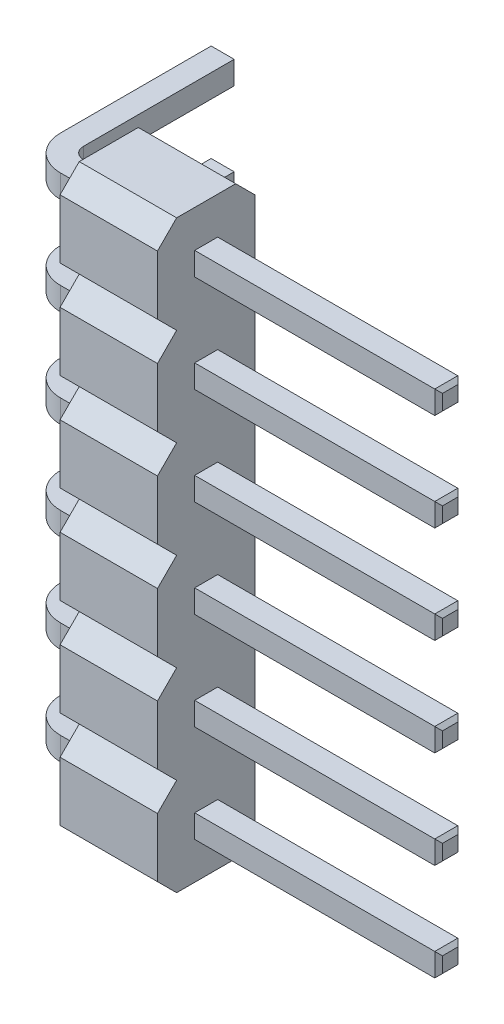
from build123d import *

# Parameters (mm, degrees)
PLASTIC_DEPTH   = 2.54
CONTACT_DEPTH   = 0.3
CHAMFER1_SIZE   = 0.1
LPATTERN1_COUNT = 6
LPATTERN1_PITCH = 2.54


with BuildPart() as part:
    # Sketch1 → Plastic (new body)
    with BuildSketch(Plane(origin=(0, 0, 0), x_dir=(0, 0, -1), z_dir=(1, 0, 0))):
        Polygon((-2.04, 1.27), (-0.5, 1.27), (0, 0.77), (0, -0.77), (-0.5, -1.27), (-2.04, -1.27), (-2.54, -0.77), (-2.54, 0.77), align=None)
    extrude(amount=PLASTIC_DEPTH)

    # Sketch2 → Contact (add, symmetric)
    with BuildSketch(Plane(origin=(0, 0, 0), x_dir=(1, 0, 0), z_dir=(0, 1, 0))):
        with BuildLine():
            Line((-1.86, 3.36), (-1.86, -0.67))
            ThreePointArc((-1.86, -0.67), (-1.596396103, -1.306396103), (-0.96, -1.57))
            Line((-0.96, -1.57), (8.9, -1.57))
            Line((8.9, -1.57), (8.9, -0.97))
            Line((8.9, -0.97), (-0.96, -0.97))
            ThreePointArc((-0.96, -0.97), (-1.172132034, -0.882132034), (-1.26, -0.67))
            Line((-1.26, -0.67), (-1.26, 3.36))
            Line((-1.26, 3.36), (-1.86, 3.36))
        make_face()
    extrude(amount=CONTACT_DEPTH, both=True)

    # Chamfer1
    chamfer1_edges = [part.edges().sort_by_distance(p)[0] for p in [
        (8.9, 0.3, 1.27),
        (8.9, 0, 1.57),
        (8.9, -0.3, 1.27),
        (8.9, 0, 0.97),
        (-1.56, 0.3, -3.36),
        (-1.26, 0, -3.36),
        (-1.86, 0, -3.36),
        (-1.56, -0.3, -3.36),
    ]]
    chamfer(chamfer1_edges, length=CHAMFER1_SIZE)

    # LPattern1: part ×6


with BuildPart() as part_1:
    add(part.part)
    with Locations(*[(0, i * LPATTERN1_PITCH, 0) for i in range(1, LPATTERN1_COUNT)]):
        add(part.part)


solid = part_1.part
